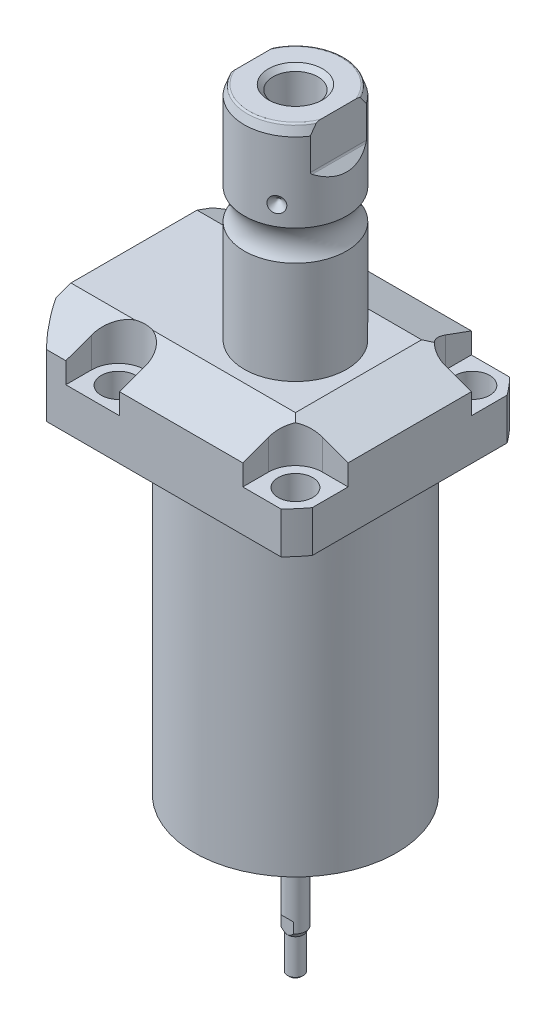
from build123d import *

# Parameters (mm, degrees)
SKETCH1_W                = 70.866
SKETCH1_H                = 85.496
EXTRUDE1_DEPTH           = 122.047
SKETCH2_OUTSIDE_W        = 120.498
SKETCH2_OUTSIDE_H        = 105.868
SKETCH2_OUTSIDE_R        = 50.8
CUT_EXTRUDE1_DEPTH       = 123.047
SKETCH3_W                = 45.1992
SKETCH3_H                = 96.9518
FILLET1_R                = 0.381
CUT_EXTRUDE2_DEPTH       = 12.243
CUT_EXTRUDE9_START       = -51.063
CUT_EXTRUDE9_DEPTH       = 87.496
CUT_EXTRUDE7_DEPTH       = 36.433
CUT_EXTRUDE7_DEPTH_BACK  = 36.433
SKETCH10_R               = 1.1811
SKETCH17_W               = 5.3594
SKETCH17_H               = 12.8522
HOLE1_AT_2_COUNT         = 2
HOLE1_AT_2_PITCH         = 54.864
HOLE1_AT_3_COUNT         = 2
HOLE1_AT_3_PITCH         = 77.589412886
HOLE1_AT_4_COUNT         = 2
HOLE1_AT_4_PITCH         = 54.864
CHAMFER1_SIZE            = 0.635
FILLET2_R                = 0.635
CIRPATTERN1_COUNT        = 3
CUT_EXTRUDE10_DEPTH      = 36.433
CUT_EXTRUDE10_DEPTH_BACK = 36.433
CHAMFER2_SIZE            = 1.4351
SKETCH30_R               = 1.27
CUT_EXTRUDE11_DEPTH      = 7.62
SKETCH31_W               = 2.7051
SKETCH31_H               = 1.3208
CUT_EXTRUDE12_DEPTH      = 3.175


with BuildPart() as part:
    # Sketch1 → Extrude1 (new body)
    with BuildSketch(Plane(origin=(0, 0, 0), x_dir=(0, 0, 1), z_dir=(0, -1, 0))):
        with Locations((0, 7.315)):
            Rectangle(SKETCH1_W, SKETCH1_H)
    extrude(amount=-EXTRUDE1_DEPTH)

    # Sketch2 outside → Cut-Extrude1 (cut, through all)
    with BuildSketch(Plane.XZ):
        with Locations((-7.315, 0)):
            Rectangle(SKETCH2_OUTSIDE_W, SKETCH2_OUTSIDE_H)
        with Locations((-5.4102, 0)):
            Circle(SKETCH2_OUTSIDE_R, mode=Mode.SUBTRACT)
    extrude(amount=-CUT_EXTRUDE1_DEPTH, mode=Mode.SUBTRACT)

    # Sketch3 → Cut-Revolve1 (revolve, cut)
    with BuildSketch(Plane(origin=(0, 0, 0), x_dir=(0, 0, -1), z_dir=(1, 0, 0))):
        with Locations((53.9941, 48.4759)):
            Rectangle(SKETCH3_W, SKETCH3_H)
    revolve(axis=Axis((0, -93.345, 0), (0, 1, 0)), mode=Mode.SUBTRACT)

    # Fillet1
    fillet1_edges = [part.edges().sort_by_distance(p)[0] for p in [
        (0, 96.9518, 31.3945),
    ]]
    fillet(fillet1_edges, radius=FILLET1_R)

    # Sketch4 → Cut-Extrude2 (cut)
    with BuildSketch(Plane(origin=(0, 122.047, 0), x_dir=(-1, 0, 0), z_dir=(0, 1, 0))):
        with BuildLine():
            Line((-19.1008, -35.433), (-19.1008, -27.432))
            ThreePointArc((-19.1008, -27.432), (-21.540951985, -21.540951985), (-27.432, -19.1008))
            Line((-27.432, -19.1008), (-35.433, -19.1008))
            Line((-35.433, -19.1008), (-35.433, -35.433))
            Line((-35.433, -35.433), (-19.1008, -35.433))
        make_face()
        with BuildLine():
            Line((35.7632, -35.433), (19.1008, -35.433))
            Line((19.1008, -35.433), (19.1008, -27.432))
            ThreePointArc((19.1008, -27.432), (27.432, -19.1008), (35.7632, -27.432))
            Line((35.7632, -27.432), (35.7632, -35.433))
        make_face()
        with BuildLine():
            Line((19.1008, 35.433), (19.1008, 27.432))
            ThreePointArc((19.1008, 27.432), (27.432, 19.1008), (35.7632, 27.432))
            Line((35.7632, 27.432), (35.7632, 35.433))
            Line((35.7632, 35.433), (19.1008, 35.433))
        make_face()
        with BuildLine():
            Line((-27.432, 19.1008), (-35.433, 19.1008))
            Line((-35.433, 19.1008), (-35.433, 35.433))
            Line((-35.433, 35.433), (-19.1008, 35.433))
            Line((-19.1008, 35.433), (-19.1008, 27.432))
            ThreePointArc((-19.1008, 27.432), (-21.540951985, 21.540951985), (-27.432, 19.1008))
        make_face()
    extrude(amount=-CUT_EXTRUDE2_DEPTH, mode=Mode.SUBTRACT)

    # Sketch5 → Cut-Extrude9 (cut)
    with BuildSketch(Plane(origin=(0, 0, 0), x_dir=(0, 0, -1), z_dir=(1, 0, 0)).offset(CUT_EXTRUDE9_START)):
        Polygon((-19.558, 122.047), (-35.433, 116.268972531), (-35.433, 122.047), align=None)
    cut_extrude9 = extrude(amount=CUT_EXTRUDE9_DEPTH, mode=Mode.SUBTRACT)

    # Mirror1: Cut-Extrude9 across plane
    add(cut_extrude9.mirror(Plane.XY), mode=Mode.SUBTRACT)

    # Sketch9 → Cut-Extrude7 (cut, two sides)
    with BuildSketch(Plane.XY) as cut_extrude7_sk:
        Polygon((19.558, 122.047), (35.433, 116.268972531), (35.433, 122.047), align=None)
    extrude(amount=CUT_EXTRUDE7_DEPTH, mode=Mode.SUBTRACT)
    extrude(cut_extrude7_sk.sketch, amount=-CUT_EXTRUDE7_DEPTH_BACK, mode=Mode.SUBTRACT)

    # Sketch20 → Cut-Revolve4 (revolve, cut)
    with BuildSketch(Plane(origin=(-35.0774, 88.9, -18.1102), x_dir=(0, 1, 0), z_dir=(1, 0, 0)), mode=Mode.PRIVATE) as cut_revolve4_sk:
        Polygon((8.0518, 38.3413), (9.4996, 38.3413), (9.4996, 35.8902), (10.5156, 35.8902), (10.5156, 33.8836), (21.4884, 33.8836), (21.4884, 32.639), (8.0518, 32.639), align=None)
    cut_revolve4 = revolve(cut_revolve4_sk.sketch.rotate(Axis((-35.0774, 81.620304954, 14.5288), (0, 1, 0)), 180), axis=Axis((-35.0774, 81.620304954, 14.5288), (0, 1, 0)), mode=Mode.SUBTRACT)  # turned: the seam where the file's is

    # Mirror10: Cut-Revolve4 across plane
    add(cut_revolve4.mirror(Plane.XY), mode=Mode.SUBTRACT)

    # Sketch15 → Revolve3 (revolve)
    with BuildSketch(Plane(origin=(0, 0, 0), x_dir=(0, 0, -1), z_dir=(1, 0, 0)), mode=Mode.PRIVATE) as revolve3_sk:
        with BuildLine():
            Line((0, 122.047), (15.875, 122.047))
            Line((15.875, 122.047), (15.875, 153.81390643))
            ThreePointArc((15.875, 153.81390643), (14.3256, 158.521), (15.875, 163.22809357))
            Line((15.875, 163.22809357), (15.875, 187.70599416))
            Line((15.875, 187.70599416), (14.81184082, 190.627))
            Line((14.81184082, 190.627), (0, 190.627))
            Line((0, 190.627), (0, 122.047))
        make_face()
    revolve(revolve3_sk.sketch.rotate(Axis((0, 250.290824608, 0), (0, -1, 0)), 180), axis=Axis((0, 250.290824608, 0), (0, -1, 0)))  # turned: the seam where the file's is

    # Sketch17 → Hole1 (revolve, cut)
    with BuildSketch(Plane(origin=(27.432, 109.804, -27.432), x_dir=(0, 0, 1), z_dir=(1, 0, 0))):
        with Locations((2.6797, 6.4261)):
            Rectangle(SKETCH17_W, SKETCH17_H)
    hole1 = revolve(axis=Axis((27.432, -0.196, -27.432), (0, 1, 0)), mode=Mode.SUBTRACT)

    # Hole1 at 2: Hole1 ×2
    with Locations(*[(0, 0, i * HOLE1_AT_2_PITCH) for i in range(1, HOLE1_AT_2_COUNT)]):
        add(hole1, mode=Mode.SUBTRACT)

    # Hole1 at 3: Hole1 ×2
    with Locations(*[Vector(-0.707106781, 0, 0.707106781) * (i * HOLE1_AT_3_PITCH) for i in range(1, HOLE1_AT_3_COUNT)]):
        add(hole1, mode=Mode.SUBTRACT)

    # Hole1 at 4: Hole1 ×2
    with Locations(*[(-i * HOLE1_AT_4_PITCH, 0, 0) for i in range(1, HOLE1_AT_4_COUNT)]):
        add(hole1, mode=Mode.SUBTRACT)

    # Chamfer1
    chamfer1_edges = [part.edges().sort_by_distance(p)[0] for p in [
        (-35.0774, 99.4156, 15.7734),
        (-35.0774, 99.4156, -15.7734),
    ]]
    chamfer(chamfer1_edges, length=CHAMFER1_SIZE)

    # Sketch21 → Cut-Revolve5 (revolve, cut)
    with BuildSketch(Plane.XZ.offset(-109.4486)):
        Polygon((-50.063, -1.9304), (-49.809, -1.9304), (-49.809, -6.7564), (-47.2563, -7.440393904), (-46.695693904, -8.001), (-30.759, -8.001), (-30.759, -12.9794), (-50.063, -12.9794), align=None)
    cut_revolve5 = revolve(axis=Axis((-57.549532301, 109.4486, -12.9794), (1, 0, 0)), mode=Mode.SUBTRACT)

    # Mirror13: Cut-Revolve5 across plane
    add(cut_revolve5.mirror(Plane.XY), mode=Mode.SUBTRACT)

    # Fillet2
    fillet2_edges = [part.edges().sort_by_distance(p)[0] for p in [
        (0, 190.627, -14.81184082),
    ]]
    fillet(fillet2_edges, radius=FILLET2_R)

    # Sketch26 → Cut-Revolve7 (revolve, cut)
    with BuildSketch(Plane.XY, mode=Mode.PRIVATE) as cut_revolve7_sk:
        Polygon((-15.875, 171.602), (-13.462, 169.189), (-15.875, 169.189), align=None)
    cut_revolve7 = revolve(cut_revolve7_sk.sketch.rotate(Axis((-39.772000707, 169.189, 0), (1, 0, 0)), 90), axis=Axis((-39.772000707, 169.189, 0), (1, 0, 0)), mode=Mode.SUBTRACT)  # turned: the seam where the file's is

    # CirPattern1: Cut-Revolve7 ×3 about axis
    cirpattern1_axis = Axis((0, 250.290824608, 0), (0, 1, 0))
    for i in range(1, CIRPATTERN1_COUNT):
        add(cut_revolve7.rotate(cirpattern1_axis, i * 360 / CIRPATTERN1_COUNT), mode=Mode.SUBTRACT)

    # Sketch27 → Hole2 (revolve, cut)
    with BuildSketch(Plane(origin=(0, 190.627, 0), x_dir=(0, 0, 1), z_dir=(1, 0, 0))):
        Polygon((0, 0), (0, 28.812118634), (6.9469, 24.638), (6.9469, 0), align=None)
    revolve(axis=Axis((0, 194.871199587, 0), (0, -1, 0)), mode=Mode.SUBTRACT)

    # Sketch29 → Cut-Extrude10 (cut, two sides)
    with BuildSketch(Plane.XY) as cut_extrude10_sk:
        with BuildLine():
            Line((13.284, 190.627), (13.284, 177.927))
            ThreePointArc((13.284, 177.927), (13.342003912, 177.635394643), (13.507185078, 177.388183558))
            Line((13.507185078, 177.388183558), (16.332, 174.563368636))
            Line((16.332, 174.563368636), (16.332, 190.627))
            Line((16.332, 190.627), (13.284, 190.627))
        make_face()
        with BuildLine():
            Line((-16.332, 190.627), (-13.284, 190.627))
            Line((-13.284, 190.627), (-13.284, 177.927))
            ThreePointArc((-13.284, 177.927), (-13.342003912, 177.635394643), (-13.507185078, 177.388183558))
            Line((-13.507185078, 177.388183558), (-16.332, 174.563368636))
            Line((-16.332, 174.563368636), (-16.332, 190.627))
        make_face()
    extrude(amount=CUT_EXTRUDE10_DEPTH, mode=Mode.SUBTRACT)
    extrude(cut_extrude10_sk.sketch, amount=-CUT_EXTRUDE10_DEPTH_BACK, mode=Mode.SUBTRACT)

    # Chamfer2
    chamfer2_edges = [part.edges().sort_by_distance(p)[0] for p in [
        (0, 190.627, -6.9469),
    ]]
    chamfer(chamfer2_edges, length=CHAMFER2_SIZE)

    # Sketch30 → Cut-Extrude11 (cut)
    with BuildSketch(Plane.XZ):
        with Locations(Location((19.431, 0, 0), (0, 0, 270))):  # turned: the seam where the file's is
            Circle(SKETCH30_R)
        with Locations(Location((18.768904731, -5.029112865, 0), (0, 0, 270))):  # turned: the seam where the file's is
            Circle(SKETCH30_R)
        with Locations(Location((-9.7155, -16.827739621, 0), (0, 0, 270))):  # turned: the seam where the file's is
            Circle(SKETCH30_R)
        with Locations(Location((-13.739791865, -13.739791865, 0), (0, 0, 270))):  # turned: the seam where the file's is
            Circle(SKETCH30_R)
        with Locations(Location((-9.7155, 16.827739621, 0), (0, 0, 270))):  # turned: the seam where the file's is
            Circle(SKETCH30_R)
        with Locations(Location((-5.029112865, 18.768904731, 0), (0, 0, 270))):  # turned: the seam where the file's is
            Circle(SKETCH30_R)
    extrude(amount=-CUT_EXTRUDE11_DEPTH, mode=Mode.SUBTRACT)

    # Sketch31 → Cut-Revolve8 (revolve, cut)
    with BuildSketch(Plane(origin=(0, 0, 0), x_dir=(0, 0, -1), z_dir=(1, 0, 0)), mode=Mode.PRIVATE) as cut_revolve8_sk:
        with Locations((12.99845, 0.6604)):
            Rectangle(SKETCH31_W, SKETCH31_H)
    revolve(cut_revolve8_sk.sketch.rotate(Axis((0, 61.617584575, 0), (0, -1, 0)), 180), axis=Axis((0, 61.617584575, 0), (0, -1, 0)), mode=Mode.SUBTRACT)  # turned: the seam where the file's is

    # Sketch32 → Revolve5 (revolve)
    with BuildSketch(Plane(origin=(0, 0, 0), x_dir=(0, 0, -1), z_dir=(1, 0, 0)), mode=Mode.PRIVATE) as revolve5_sk:
        Polygon((3.175, 0), (3.175, -35.249371375), (2.4384, -36.5252), (2.4384, -47.4472), (1.9304, -47.9552), (0, -47.9552), (0, 0), align=None)
    revolve(revolve5_sk.sketch.rotate(Axis((0, 46.642918558, 0), (0, -1, 0)), 180), axis=Axis((0, 46.642918558, 0), (0, -1, 0)))  # turned: the seam where the file's is

    # Sketch33 → Cut-Extrude12 (cut, symmetric)
    with BuildSketch(Plane(origin=(0, 0, 0), x_dir=(0, 0, -1), z_dir=(1, 0, 0))):
        Polygon((2.5019, -36.415214774), (2.5019, -32.0802), (3.2639, -31.3182), (3.2639, -36.415214774), align=None)
    cut_extrude12 = extrude(amount=CUT_EXTRUDE12_DEPTH, both=True, mode=Mode.SUBTRACT)

    # Mirror14: Cut-Extrude12 across plane
    add(cut_extrude12.mirror(Plane.XY), mode=Mode.SUBTRACT)


with BuildPart() as body_2:
    # Sketch10 → Revolve4 (revolve)
    with BuildSketch(Plane(origin=(-35.0774, 88.9, -18.1102), x_dir=(0, 1, 0), z_dir=(1, 0, 0))):
        with Locations((8.3185, 8.1026)):
            Circle(SKETCH10_R)
    revolve(axis=Axis((-35.0774, 87.86749, -14.5288), (0, 1, 0)))


with BuildPart() as body_3:
    # Mirror12: mirrored copy
    add(body_2.part.mirror(Plane.XY))


solid = Compound([part.part, body_2.part, body_3.part])
